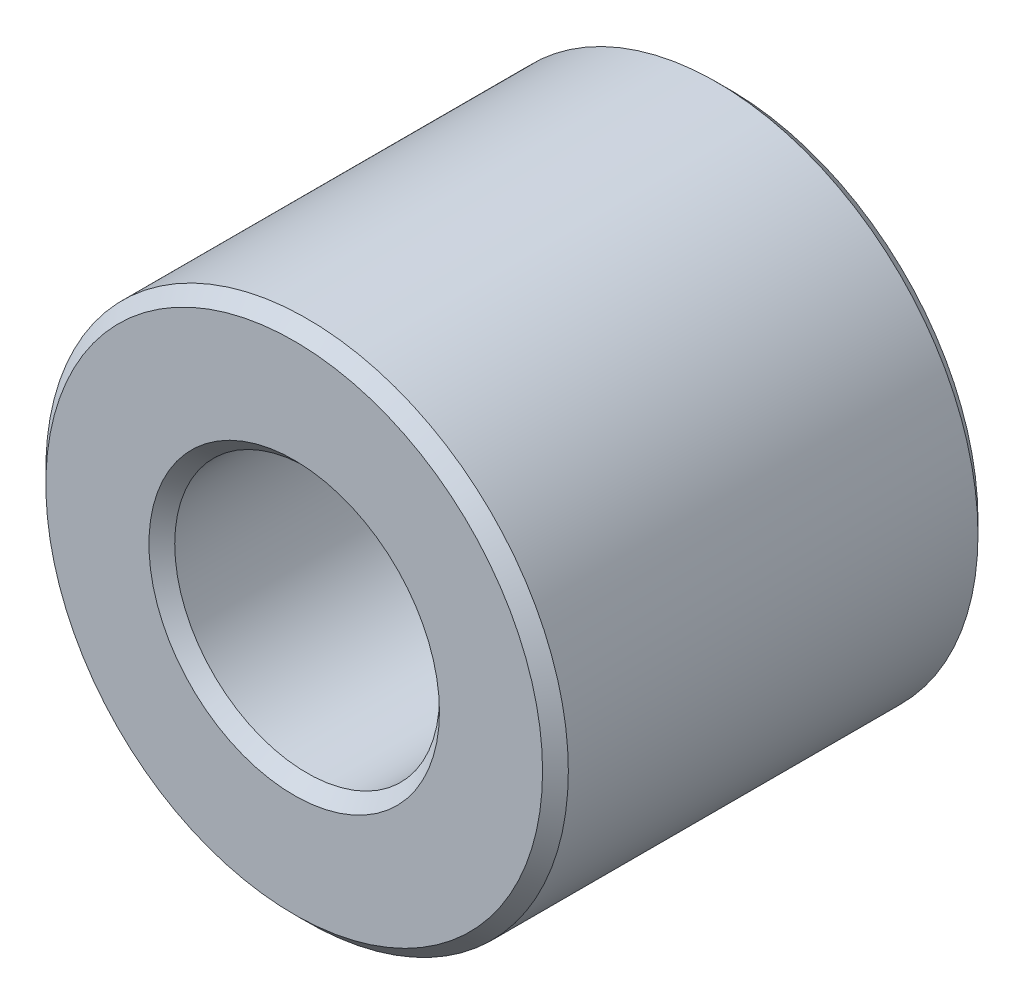
from build123d import *

# Parameters (mm, degrees)
BOSS_EXTRUDE1_DEPTH      = 7.9375
BOSS_EXTRUDE1_DEPTH_BACK = 7.9375
SKETCH3_R                = 9.525
SKETCH3_R_2              = 4.826
CHAMFER1_SIZE            = 0.4699


with BuildPart() as part:
    # Sketch3 → Boss-Extrude1 (new, two sides: drawn at the far end of the back side and taken through both)
    with BuildSketch(Plane.XY.offset(-BOSS_EXTRUDE1_DEPTH_BACK)):
        Circle(SKETCH3_R)
        Circle(SKETCH3_R_2, mode=Mode.SUBTRACT)
    extrude(amount=BOSS_EXTRUDE1_DEPTH + BOSS_EXTRUDE1_DEPTH_BACK)

    # Chamfer1
    chamfer1_edges = [part.edges().sort_by_distance(p)[0] for p in [
        (-9.525, 0, -7.9375),
        (-4.826, 0, -7.9375),
        (-9.525, 0, 7.9375),
        (-4.826, 0, 7.9375),
    ]]
    chamfer(chamfer1_edges, length=CHAMFER1_SIZE)


solid = part.part
